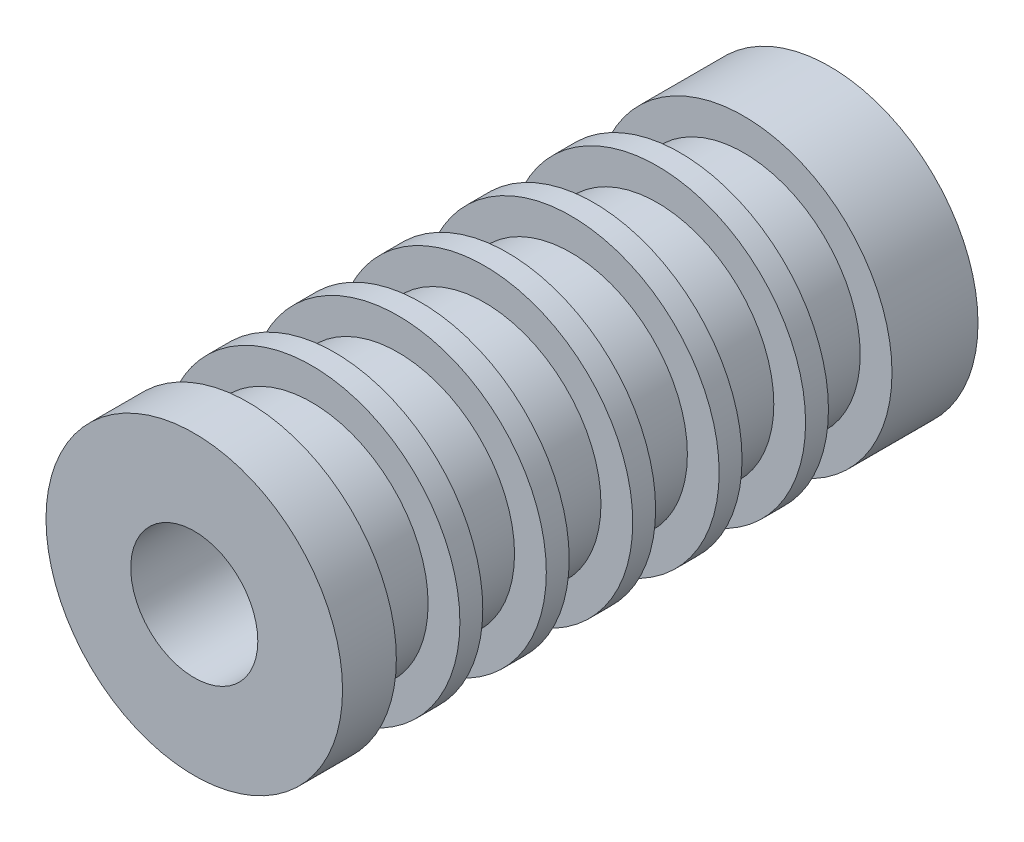
from build123d import *

# Parameters (mm, degrees)
SKETCH1_R          = 11.1125
SKETCH1_R_2        = 3.2004
EXTRUDE1_DEPTH     = 25.4
SKETCH5_R          = 11.1125
SKETCH5_R_2        = 3.2004
CUT_EXTRUDE1_DEPTH = 3.175
SKETCH6_R          = 4.7625
CUT_EXTRUDE2_DEPTH = 48.625
CUT_EXTRUDE3_START = -6.44525
SKETCH7_R          = 11.1125
SKETCH7_R_2        = 8.73125
CUT_EXTRUDE3_DEPTH = 4.7625
LPATTERN1_COUNT    = 6
LPATTERN1_PITCH    = 6.477


with BuildPart() as part:
    # Sketch1 → Extrude1 (new body, symmetric)
    with BuildSketch(Plane.XY):
        Circle(SKETCH1_R)
        Circle(SKETCH1_R_2, mode=Mode.SUBTRACT)
    extrude(amount=EXTRUDE1_DEPTH, both=True)

    # Sketch5 → Cut-Extrude1 (cut)
    with BuildSketch(Plane.XY.offset(25.4)):
        Circle(SKETCH5_R)
        Circle(SKETCH5_R_2, mode=Mode.SUBTRACT)
    extrude(amount=-CUT_EXTRUDE1_DEPTH, mode=Mode.SUBTRACT)

    # Sketch6 → Cut-Extrude2 (cut, through all)
    with BuildSketch(Plane.XY.offset(22.225)):
        Circle(SKETCH6_R)
    extrude(amount=-CUT_EXTRUDE2_DEPTH, mode=Mode.SUBTRACT)

    # Sketch7 → Cut-Extrude3 (cut)
    with BuildSketch(Plane(origin=(0, 0, -25.4), x_dir=(-1, 0, 0), z_dir=(0, 0, -1)).offset(CUT_EXTRUDE3_START)):
        Circle(SKETCH7_R)
        Circle(SKETCH7_R_2, mode=Mode.SUBTRACT)
    cut_extrude3 = extrude(amount=-CUT_EXTRUDE3_DEPTH, mode=Mode.SUBTRACT)

    # LPattern1: Cut-Extrude3 ×6
    with Locations(*[(0, 0, i * LPATTERN1_PITCH) for i in range(1, LPATTERN1_COUNT)]):
        add(cut_extrude3, mode=Mode.SUBTRACT)


solid = part.part
